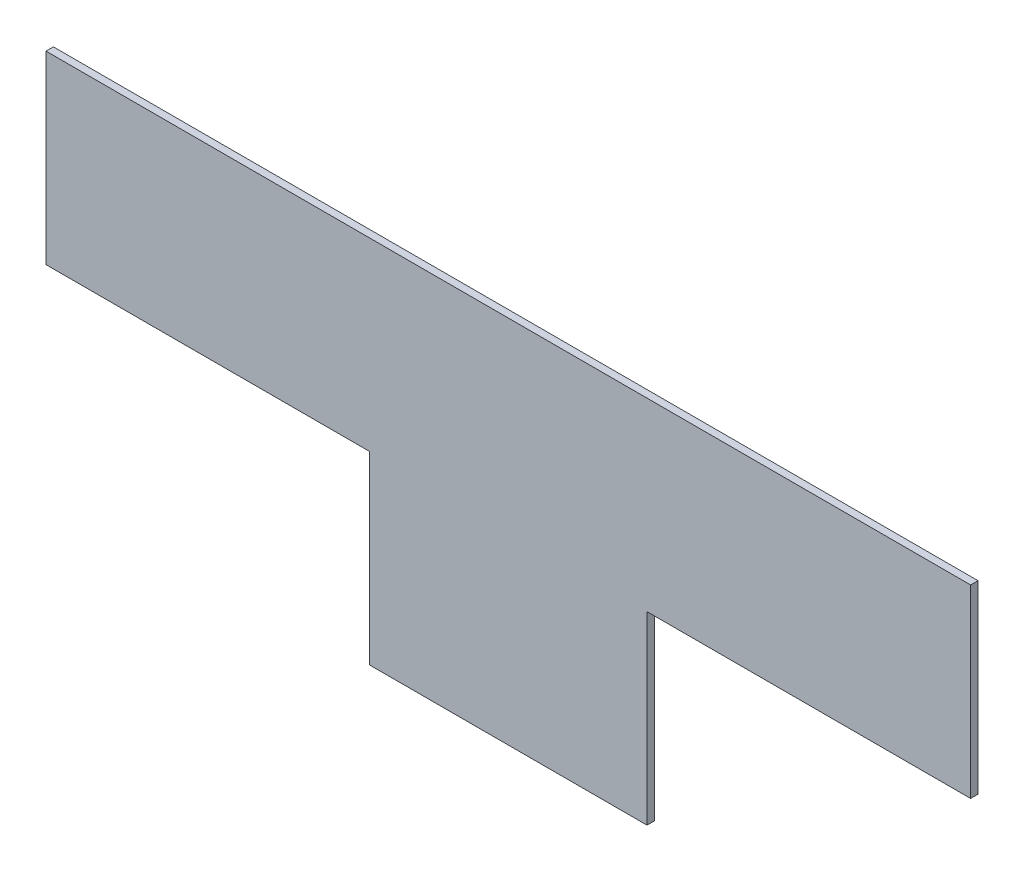
from build123d import *

# Parameters (mm, degrees)
SKIZZE1_W                       = 2000
SKIZZE1_H                       = 800
AUFSATZ_LINEAR_AUSTRAGEN1_DEPTH = 16
SCHNITT_LINEAR_AUSTRAGEN1_DEPTH = 17


with BuildPart() as part:
    # Skizze1 → Aufsatz-Linear austragen1 (new body)
    with BuildSketch(Plane.XY):
        Rectangle(SKIZZE1_W, SKIZZE1_H)
    extrude(amount=AUFSATZ_LINEAR_AUSTRAGEN1_DEPTH)

    # Skizze2 → Schnitt-Linear austragen1 (cut, through all)
    with BuildSketch(Plane.XY.offset(16)):
        Polygon((-300, -400), (-300, 0), (-1381.908908696, 0), (-1381.908908696, -457.580605906), (-300, -457.580605906), align=None)
        Polygon((1381.908908696, -457.580605906), (300, -457.580605906), (300, -400), (300, 0), (1381.908908696, 0), align=None)
    extrude(amount=-SCHNITT_LINEAR_AUSTRAGEN1_DEPTH, mode=Mode.SUBTRACT)


solid = part.part
